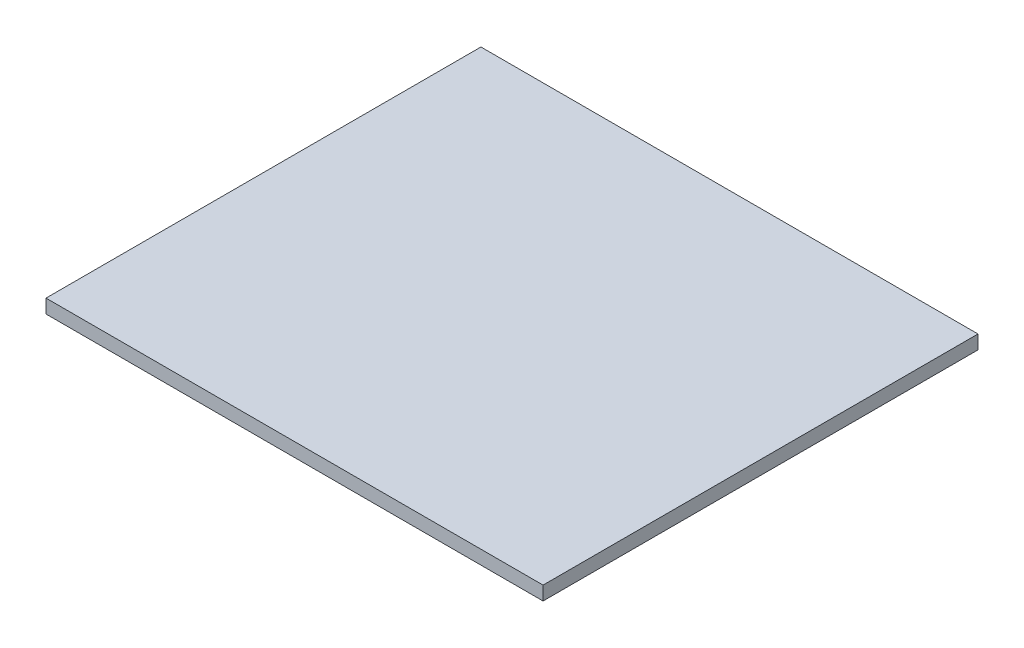
from build123d import *

# Parameters (mm, degrees)
SKETCH1_W           = 720
SKETCH1_H           = 630
BOSS_EXTRUDE1_DEPTH = 20


with BuildPart() as part:
    # Sketch1 → Boss-Extrude1 (new body)
    with BuildSketch(Plane(origin=(0, 0, 0), x_dir=(1, 0, 0), z_dir=(0, 1, 0))):
        Rectangle(SKETCH1_W, SKETCH1_H)
    extrude(amount=BOSS_EXTRUDE1_DEPTH)


solid = part.part
